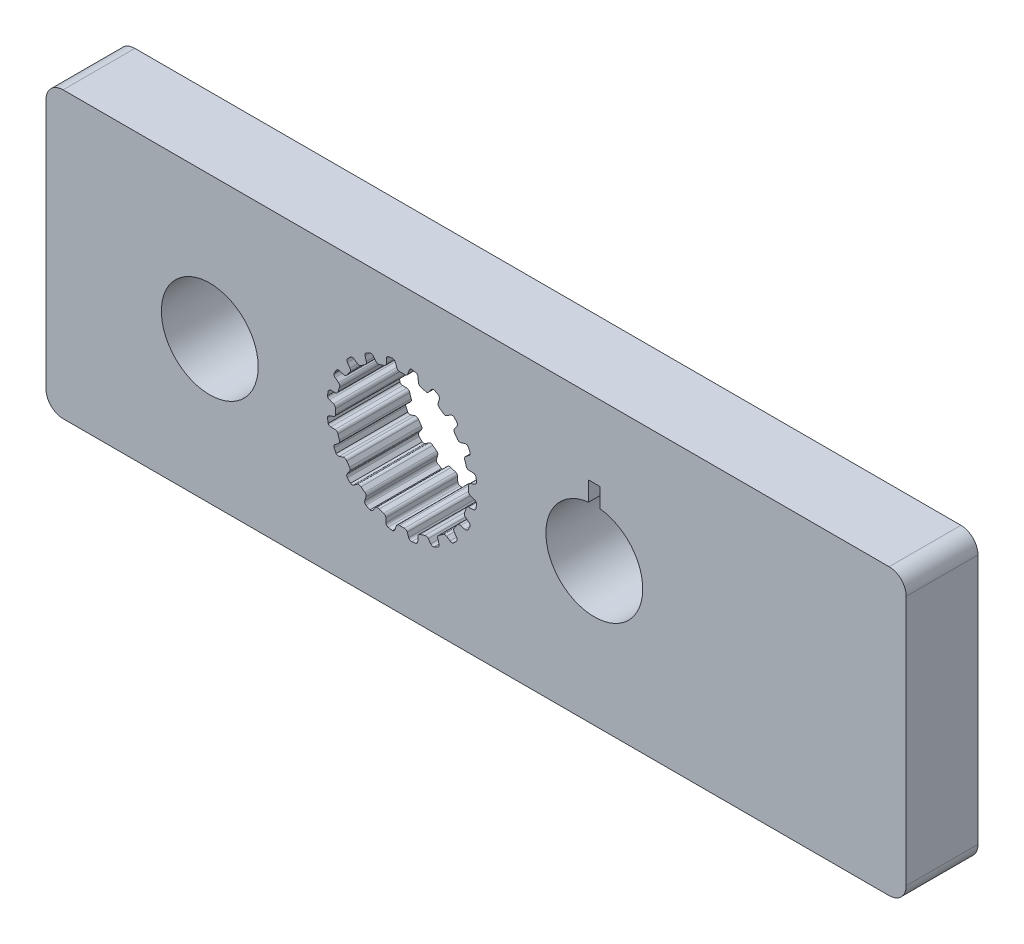
from build123d import *

# Parameters (mm, degrees)
SKETCH1_W           = 38.354
SKETCH1_H           = 12.7
SKETCH1_R           = 2.159
BOSS_EXTRUDE1_DEPTH = 1.6002
SKETCH2_W           = 0.508
SKETCH2_H           = 1.27
CUT_EXTRUDE1_DEPTH  = 3.2004
FILLET1_R           = 0.762


with BuildPart() as part:
    # Sketch1 → Boss-Extrude1 (new body, symmetric)
    with BuildSketch(Plane.XY):
        with Locations((3.302, 0)):
            Rectangle(SKETCH1_W, SKETCH1_H)
        with Locations((-8.5725, 0)):
            Circle(SKETCH1_R, mode=Mode.SUBTRACT)
        with Locations((8.5725, 0)):
            Circle(SKETCH1_R, mode=Mode.SUBTRACT)
        with BuildLine():
            Line((-0.106949245, 2.969874934), (0.106949245, 2.969874934))
            ThreePointArc((0.106949245, 2.969874934), (0.196343213, 2.986924176), (0.253739238, 3.057547504))
            Line((0.253739238, 3.057547504), (0.315888147, 3.237526941))
            ThreePointArc((0.315888147, 3.237526941), (0.359032156, 3.298322911), (0.4281449, 3.326269005))
            Line((0.4281449, 3.326269005), (0.620027588, 3.2937547))
            ThreePointArc((0.620027588, 3.2937547), (0.689621142, 3.24802576), (0.718272212, 3.169836791))
            Line((0.718272212, 3.169836791), (0.724389167, 2.979527391))
            ThreePointArc((0.724389167, 2.979527391), (0.750934762, 2.9040661), (0.816027049, 2.857568043))
            Line((0.816027049, 2.857568043), (1.019456602, 2.791469774))
            ThreePointArc((1.019456602, 2.791469774), (1.109743823, 2.780060312), (1.186154496, 2.829490741))
            Line((1.186154496, 2.829490741), (1.300878326, 2.981456288))
            ThreePointArc((1.300878326, 2.981456288), (1.360697704, 3.02594446), (1.435063648, 3.031165762))
            Line((1.435063648, 3.031165762), (1.607507455, 2.940947809))
            ThreePointArc((1.607507455, 2.940947809), (1.659563839, 2.875951412), (1.662650905, 2.792735615))
            Line((1.662650905, 2.792735615), (1.609659636, 2.609850378))
            ThreePointArc((1.609659636, 2.609850378), (1.611587176, 2.529879385), (1.659124931, 2.465542482))
            Line((1.659124931, 2.465542482), (1.832172444, 2.339816104))
            ThreePointArc((1.832172444, 2.339816104), (1.914514976, 2.301064775), (2.002460687, 2.32446371))
            Line((2.002460687, 2.32446371), (2.158529469, 2.433539921))
            ThreePointArc((2.158529469, 2.433539921), (2.229168681, 2.457365482), (2.301508367, 2.439350895))
            Line((2.301508367, 2.439350895), (2.437633293, 2.300260456))
            ThreePointArc((2.437633293, 2.300260456), (2.467056864, 2.222358901), (2.444277744, 2.14226202))
            Line((2.444277744, 2.14226202), (2.337365406, 1.984703026))
            ThreePointArc((2.337365406, 1.984703026), (2.314486209, 1.908050449), (2.339816104, 1.832172444))
            Line((2.339816104, 1.832172444), (2.465542482, 1.659124931))
            ThreePointArc((2.465542482, 1.659124931), (2.531880064, 1.596824985), (2.622752074, 1.591901975))
            Line((2.622752074, 1.591901975), (2.804888709, 1.64741171))
            ThreePointArc((2.804888709, 1.64741171), (2.879433095, 1.648242449), (2.942665411, 1.608755366))
            Line((2.942665411, 1.608755366), (3.0291466, 1.434407582))
            ThreePointArc((3.0291466, 1.434407582), (3.033057175, 1.351226417), (2.986641646, 1.282088892))
            Line((2.986641646, 1.282088892), (2.836273564, 1.165279113))
            ThreePointArc((2.836273564, 1.165279113), (2.790827206, 1.099448241), (2.791469774, 1.019456602))
            Line((2.791469774, 1.019456602), (2.857568043, 0.816027049))
            ThreePointArc((2.857568043, 0.816027049), (2.901407091, 0.736276839), (2.986310214, 0.703513784))
            Line((2.986310214, 0.703513784), (3.1766859, 0.700023363))
            ThreePointArc((3.1766859, 0.700023363), (3.247838536, 0.677777961), (3.295773863, 0.620683653))
            Line((3.295773863, 0.620683653), (3.324145932, 0.4281449))
            ThreePointArc((3.324145932, 0.4281449), (3.302160717, 0.347826477), (3.236652255, 0.29641597))
            Line((3.236652255, 0.29641597), (3.057547504, 0.231789562))
            ThreePointArc((3.057547504, 0.231789562), (2.993982591, 0.183224379), (2.969874934, 0.106949245))
            Line((2.969874934, 0.106949245), (2.969874934, -0.106949245))
            ThreePointArc((2.969874934, -0.106949245), (2.986924176, -0.196343213), (3.057547504, -0.253739238))
            Line((3.057547504, -0.253739238), (3.237526941, -0.315888147))
            ThreePointArc((3.237526941, -0.315888147), (3.298322911, -0.359032156), (3.326269005, -0.4281449))
            Line((3.326269005, -0.4281449), (3.2937547, -0.620027588))
            ThreePointArc((3.2937547, -0.620027588), (3.24802576, -0.689621142), (3.169836791, -0.718272212))
            Line((3.169836791, -0.718272212), (2.979527391, -0.724389167))
            ThreePointArc((2.979527391, -0.724389167), (2.9040661, -0.750934762), (2.857568043, -0.816027049))
            Line((2.857568043, -0.816027049), (2.791469774, -1.019456602))
            ThreePointArc((2.791469774, -1.019456602), (2.780060312, -1.109743823), (2.829490741, -1.186154496))
            Line((2.829490741, -1.186154496), (2.981456288, -1.300878326))
            ThreePointArc((2.981456288, -1.300878326), (3.02594446, -1.360697704), (3.031165762, -1.435063648))
            Line((3.031165762, -1.435063648), (2.940947809, -1.607507455))
            ThreePointArc((2.940947809, -1.607507455), (2.875951412, -1.659563839), (2.792735615, -1.662650905))
            Line((2.792735615, -1.662650905), (2.609850378, -1.609659636))
            ThreePointArc((2.609850378, -1.609659636), (2.529879385, -1.611587176), (2.465542482, -1.659124931))
            Line((2.465542482, -1.659124931), (2.339816104, -1.832172444))
            ThreePointArc((2.339816104, -1.832172444), (2.301064775, -1.914514976), (2.32446371, -2.002460687))
            Line((2.32446371, -2.002460687), (2.433539921, -2.158529469))
            ThreePointArc((2.433539921, -2.158529469), (2.457365482, -2.229168681), (2.439350895, -2.301508367))
            Line((2.439350895, -2.301508367), (2.300260456, -2.437633293))
            ThreePointArc((2.300260456, -2.437633293), (2.222358901, -2.467056864), (2.14226202, -2.444277744))
            Line((2.14226202, -2.444277744), (1.984703026, -2.337365406))
            ThreePointArc((1.984703026, -2.337365406), (1.908050449, -2.314486209), (1.832172444, -2.339816104))
            Line((1.832172444, -2.339816104), (1.659124931, -2.465542482))
            ThreePointArc((1.659124931, -2.465542482), (1.596824985, -2.531880064), (1.591901975, -2.622752074))
            Line((1.591901975, -2.622752074), (1.64741171, -2.804888709))
            ThreePointArc((1.64741171, -2.804888709), (1.648242449, -2.879433095), (1.608755366, -2.942665411))
            Line((1.608755366, -2.942665411), (1.434407582, -3.0291466))
            ThreePointArc((1.434407582, -3.0291466), (1.351226417, -3.033057175), (1.282088892, -2.986641646))
            Line((1.282088892, -2.986641646), (1.165279113, -2.836273564))
            ThreePointArc((1.165279113, -2.836273564), (1.099448241, -2.790827206), (1.019456602, -2.791469774))
            Line((1.019456602, -2.791469774), (0.816027049, -2.857568043))
            ThreePointArc((0.816027049, -2.857568043), (0.736276839, -2.901407091), (0.703513784, -2.986310214))
            Line((0.703513784, -2.986310214), (0.700023363, -3.1766859))
            ThreePointArc((0.700023363, -3.1766859), (0.677777961, -3.247838536), (0.620683653, -3.295773863))
            Line((0.620683653, -3.295773863), (0.4281449, -3.324145932))
            ThreePointArc((0.4281449, -3.324145932), (0.347826477, -3.302160717), (0.29641597, -3.236652255))
            Line((0.29641597, -3.236652255), (0.231789562, -3.057547504))
            ThreePointArc((0.231789562, -3.057547504), (0.183224379, -2.993982591), (0.106949245, -2.969874934))
            Line((0.106949245, -2.969874934), (-0.106949245, -2.969874934))
            ThreePointArc((-0.106949245, -2.969874934), (-0.196343213, -2.986924176), (-0.253739238, -3.057547504))
            Line((-0.253739238, -3.057547504), (-0.315888147, -3.237526941))
            ThreePointArc((-0.315888147, -3.237526941), (-0.359032156, -3.298322911), (-0.4281449, -3.326269005))
            Line((-0.4281449, -3.326269005), (-0.620027588, -3.2937547))
            ThreePointArc((-0.620027588, -3.2937547), (-0.689621142, -3.24802576), (-0.718272212, -3.169836791))
            Line((-0.718272212, -3.169836791), (-0.724389167, -2.979527391))
            ThreePointArc((-0.724389167, -2.979527391), (-0.750934762, -2.9040661), (-0.816027049, -2.857568043))
            Line((-0.816027049, -2.857568043), (-1.019456602, -2.791469774))
            ThreePointArc((-1.019456602, -2.791469774), (-1.109743823, -2.780060312), (-1.186154496, -2.829490741))
            Line((-1.186154496, -2.829490741), (-1.300878326, -2.981456288))
            ThreePointArc((-1.300878326, -2.981456288), (-1.360697704, -3.02594446), (-1.435063648, -3.031165762))
            Line((-1.435063648, -3.031165762), (-1.607507455, -2.940947809))
            ThreePointArc((-1.607507455, -2.940947809), (-1.659563839, -2.875951412), (-1.662650905, -2.792735615))
            Line((-1.662650905, -2.792735615), (-1.609659636, -2.609850378))
            ThreePointArc((-1.609659636, -2.609850378), (-1.611587176, -2.529879385), (-1.659124931, -2.465542482))
            Line((-1.659124931, -2.465542482), (-1.832172444, -2.339816104))
            ThreePointArc((-1.832172444, -2.339816104), (-1.914514976, -2.301064775), (-2.002460687, -2.32446371))
            Line((-2.002460687, -2.32446371), (-2.158529469, -2.433539921))
            ThreePointArc((-2.158529469, -2.433539921), (-2.229168681, -2.457365482), (-2.301508367, -2.439350895))
            Line((-2.301508367, -2.439350895), (-2.437633293, -2.300260456))
            ThreePointArc((-2.437633293, -2.300260456), (-2.467056864, -2.222358901), (-2.444277744, -2.14226202))
            Line((-2.444277744, -2.14226202), (-2.337365406, -1.984703026))
            ThreePointArc((-2.337365406, -1.984703026), (-2.314486209, -1.908050449), (-2.339816104, -1.832172444))
            Line((-2.339816104, -1.832172444), (-2.465542482, -1.659124931))
            ThreePointArc((-2.465542482, -1.659124931), (-2.531880064, -1.596824985), (-2.622752074, -1.591901975))
            Line((-2.622752074, -1.591901975), (-2.804888709, -1.64741171))
            ThreePointArc((-2.804888709, -1.64741171), (-2.879433095, -1.648242449), (-2.942665411, -1.608755366))
            Line((-2.942665411, -1.608755366), (-3.0291466, -1.434407582))
            ThreePointArc((-3.0291466, -1.434407582), (-3.033057175, -1.351226417), (-2.986641646, -1.282088892))
            Line((-2.986641646, -1.282088892), (-2.836273564, -1.165279113))
            ThreePointArc((-2.836273564, -1.165279113), (-2.790827206, -1.099448241), (-2.791469774, -1.019456602))
            Line((-2.791469774, -1.019456602), (-2.857568043, -0.816027049))
            ThreePointArc((-2.857568043, -0.816027049), (-2.901407091, -0.736276839), (-2.986310214, -0.703513784))
            Line((-2.986310214, -0.703513784), (-3.1766859, -0.700023363))
            ThreePointArc((-3.1766859, -0.700023363), (-3.247838536, -0.677777961), (-3.295773863, -0.620683653))
            Line((-3.295773863, -0.620683653), (-3.324145932, -0.4281449))
            ThreePointArc((-3.324145932, -0.4281449), (-3.302160717, -0.347826477), (-3.236652255, -0.29641597))
            Line((-3.236652255, -0.29641597), (-3.057547504, -0.231789562))
            ThreePointArc((-3.057547504, -0.231789562), (-2.993982591, -0.183224379), (-2.969874934, -0.106949245))
            Line((-2.969874934, -0.106949245), (-2.969874934, 0.106949245))
            ThreePointArc((-2.969874934, 0.106949245), (-2.986924176, 0.196343213), (-3.057547504, 0.253739238))
            Line((-3.057547504, 0.253739238), (-3.237526941, 0.315888147))
            ThreePointArc((-3.237526941, 0.315888147), (-3.298322911, 0.359032156), (-3.326269005, 0.4281449))
            Line((-3.326269005, 0.4281449), (-3.2937547, 0.620027588))
            ThreePointArc((-3.2937547, 0.620027588), (-3.24802576, 0.689621142), (-3.169836791, 0.718272212))
            Line((-3.169836791, 0.718272212), (-2.979527391, 0.724389167))
            ThreePointArc((-2.979527391, 0.724389167), (-2.9040661, 0.750934762), (-2.857568043, 0.816027049))
            Line((-2.857568043, 0.816027049), (-2.791469774, 1.019456602))
            ThreePointArc((-2.791469774, 1.019456602), (-2.780060312, 1.109743823), (-2.829490741, 1.186154496))
            Line((-2.829490741, 1.186154496), (-2.981456288, 1.300878326))
            ThreePointArc((-2.981456288, 1.300878326), (-3.02594446, 1.360697704), (-3.031165762, 1.435063648))
            Line((-3.031165762, 1.435063648), (-2.940947809, 1.607507455))
            ThreePointArc((-2.940947809, 1.607507455), (-2.875951412, 1.659563839), (-2.792735615, 1.662650905))
            Line((-2.792735615, 1.662650905), (-2.609850378, 1.609659636))
            ThreePointArc((-2.609850378, 1.609659636), (-2.529879385, 1.611587176), (-2.465542482, 1.659124931))
            Line((-2.465542482, 1.659124931), (-2.339816104, 1.832172444))
            ThreePointArc((-2.339816104, 1.832172444), (-2.301064775, 1.914514976), (-2.32446371, 2.002460687))
            Line((-2.32446371, 2.002460687), (-2.433539921, 2.158529469))
            ThreePointArc((-2.433539921, 2.158529469), (-2.457365482, 2.229168681), (-2.439350895, 2.301508367))
            Line((-2.439350895, 2.301508367), (-2.300260456, 2.437633293))
            ThreePointArc((-2.300260456, 2.437633293), (-2.222358901, 2.467056864), (-2.14226202, 2.444277744))
            Line((-2.14226202, 2.444277744), (-1.984703026, 2.337365406))
            ThreePointArc((-1.984703026, 2.337365406), (-1.908050449, 2.314486209), (-1.832172444, 2.339816104))
            Line((-1.832172444, 2.339816104), (-1.659124931, 2.465542482))
            ThreePointArc((-1.659124931, 2.465542482), (-1.596824985, 2.531880064), (-1.591901975, 2.622752074))
            Line((-1.591901975, 2.622752074), (-1.64741171, 2.804888709))
            ThreePointArc((-1.64741171, 2.804888709), (-1.648242449, 2.879433095), (-1.608755366, 2.942665411))
            Line((-1.608755366, 2.942665411), (-1.434407582, 3.0291466))
            ThreePointArc((-1.434407582, 3.0291466), (-1.351226417, 3.033057175), (-1.282088892, 2.986641646))
            Line((-1.282088892, 2.986641646), (-1.165279113, 2.836273564))
            ThreePointArc((-1.165279113, 2.836273564), (-1.099448241, 2.790827206), (-1.019456602, 2.791469774))
            Line((-1.019456602, 2.791469774), (-0.816027049, 2.857568043))
            ThreePointArc((-0.816027049, 2.857568043), (-0.736276839, 2.901407091), (-0.703513784, 2.986310214))
            Line((-0.703513784, 2.986310214), (-0.700023363, 3.1766859))
            ThreePointArc((-0.700023363, 3.1766859), (-0.677777961, 3.247838536), (-0.620683653, 3.295773863))
            Line((-0.620683653, 3.295773863), (-0.4281449, 3.324145932))
            ThreePointArc((-0.4281449, 3.324145932), (-0.347826477, 3.302160717), (-0.29641597, 3.236652255))
            Line((-0.29641597, 3.236652255), (-0.231789562, 3.057547504))
            ThreePointArc((-0.231789562, 3.057547504), (-0.183224379, 2.993982591), (-0.106949245, 2.969874934))
        make_face(mode=Mode.SUBTRACT)
    extrude(amount=BOSS_EXTRUDE1_DEPTH, both=True)

    # Sketch2 → Cut-Extrude1 (cut)
    with BuildSketch(Plane.XY.offset(1.6002)):
        with Locations((8.5725, 2.36728)):
            Rectangle(SKETCH2_W, SKETCH2_H)
    extrude(amount=-CUT_EXTRUDE1_DEPTH, mode=Mode.SUBTRACT)

    # Fillet1
    fillet1_edges = [part.edges().sort_by_distance(p)[0] for p in [
        (-15.875, 6.35, 0),
        (22.479, 6.35, 0),
        (22.479, -6.35, 0),
        (-15.875, -6.35, 0),
    ]]
    fillet(fillet1_edges, radius=FILLET1_R)


solid = part.part
